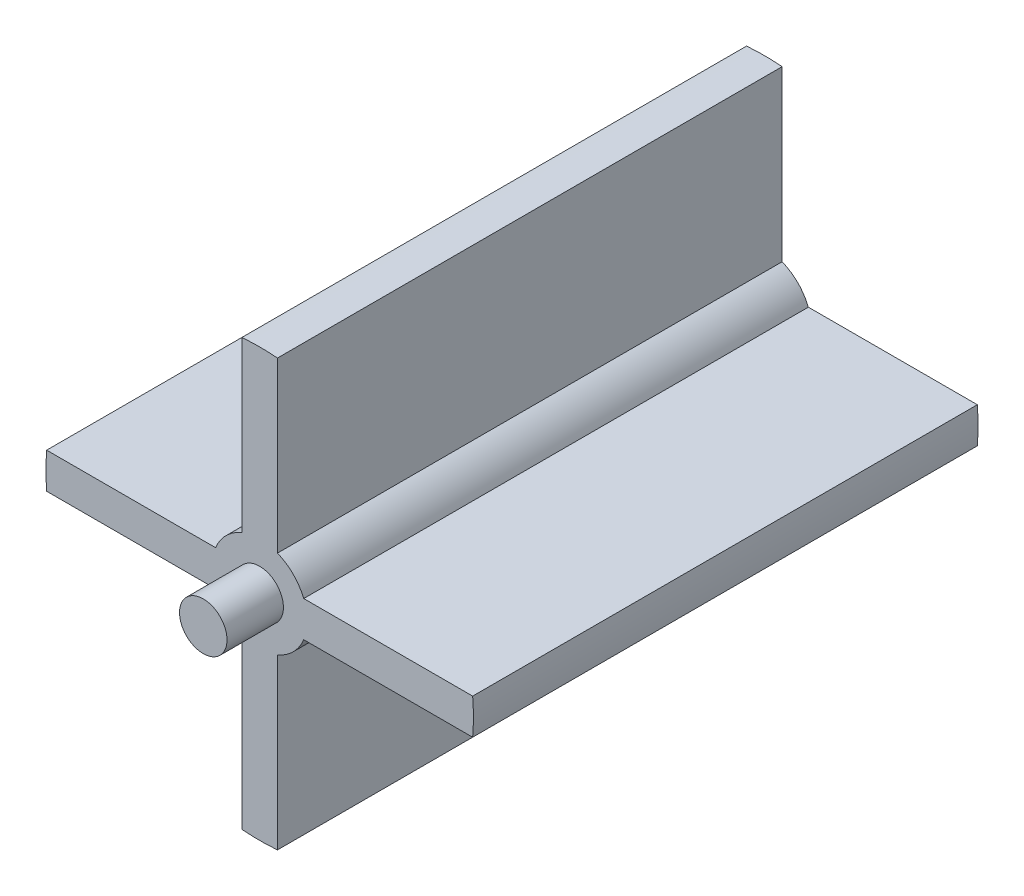
from build123d import *

# Parameters (mm, degrees)
SKETCH1_R             = 36
BOSS_EXTRUDE1_DEPTH   = 85
SKETCH3_R             = 4
CUT_EXTRUDE2_DEPTH    = 5
SKETCH4_OUTSIDE_W     = 100.528
SKETCH4_OUTSIDE_H     = 100.528
CUT_EXTRUDE3_DEPTH    = 86
SKETCH5_R             = 3.975
BOSS_EXTRUDE2_DEPTH   = 14.5
BOSS_EXTRUDE2_2_DEPTH = 14.5
SKETCH2_R             = 4
BOSS_EXTRUDE3_DEPTH   = 9.5


with BuildPart() as part:
    # Sketch1 → Boss-Extrude1 (new body)
    with BuildSketch(Plane.XY):
        Circle(SKETCH1_R)
    extrude(amount=BOSS_EXTRUDE1_DEPTH)

    # Sketch3 → Cut-Extrude2 (cut)
    with BuildSketch(Plane(origin=(0, 0, 0), x_dir=(-1, 0, 0), z_dir=(0, 0, -1))):
        Circle(SKETCH3_R)
    extrude(amount=-CUT_EXTRUDE2_DEPTH, mode=Mode.SUBTRACT)

    # Sketch4 outside → Cut-Extrude3 (cut, through all)
    with BuildSketch(Plane(origin=(0, 0, 0), x_dir=(-1, 0, 0), z_dir=(0, 0, -1))):
        Rectangle(SKETCH4_OUTSIDE_W, SKETCH4_OUTSIDE_H)
        with BuildLine():
            Line((-35.874782229, 3), (-7.416198487, 3))
            ThreePointArc((-7.416198487, 3), (-5.656854249, 5.656854249), (-3, 7.416198487))
            Line((-3, 7.416198487), (-3, 35.874782229))
            ThreePointArc((-3, 35.874782229), (0, 36), (3, 35.874782229))
            Line((3, 35.874782229), (3, 7.416198487))
            ThreePointArc((3, 7.416198487), (5.656854249, 5.656854249), (7.416198487, 3))
            Line((7.416198487, 3), (35.874782229, 3))
            ThreePointArc((35.874782229, 3), (36, 0), (35.874782229, -3))
            Line((35.874782229, -3), (7.416198487, -3))
            ThreePointArc((7.416198487, -3), (5.656854249, -5.656854249), (3, -7.416198487))
            Line((3, -7.416198487), (3, -35.874782229))
            ThreePointArc((3, -35.874782229), (0, -36), (-3, -35.874782229))
            Line((-3, -35.874782229), (-3, -7.416198487))
            ThreePointArc((-3, -7.416198487), (-5.656854249, -5.656854249), (-7.416198487, -3))
            Line((-7.416198487, -3), (-35.874782229, -3))
            ThreePointArc((-35.874782229, -3), (-36, 0), (-35.874782229, 3))
        make_face(mode=Mode.SUBTRACT)
    extrude(amount=-CUT_EXTRUDE3_DEPTH, mode=Mode.SUBTRACT)

    # Sketch2 → Boss-Extrude3 (add)
    with BuildSketch(Plane.XY.offset(85)):
        Circle(SKETCH2_R)
    extrude(amount=BOSS_EXTRUDE3_DEPTH)


with BuildPart() as body_2:
    # Sketch5 → Boss-Extrude2 (new body)
    with BuildSketch(Plane.XY):
        with Locations((-9.323429637, 9.511993383)):
            Circle(SKETCH5_R)
    extrude(amount=BOSS_EXTRUDE2_DEPTH)


with BuildPart() as body_3:
    # Sketch5 → Boss-Extrude2 2 (new body)
    with BuildSketch(Plane.XY):
        with Locations((9.53294491, -9.218672001)):
            Circle(SKETCH5_R)
    extrude(amount=BOSS_EXTRUDE2_2_DEPTH)


solid = Compound([part.part, body_2.part, body_3.part])
